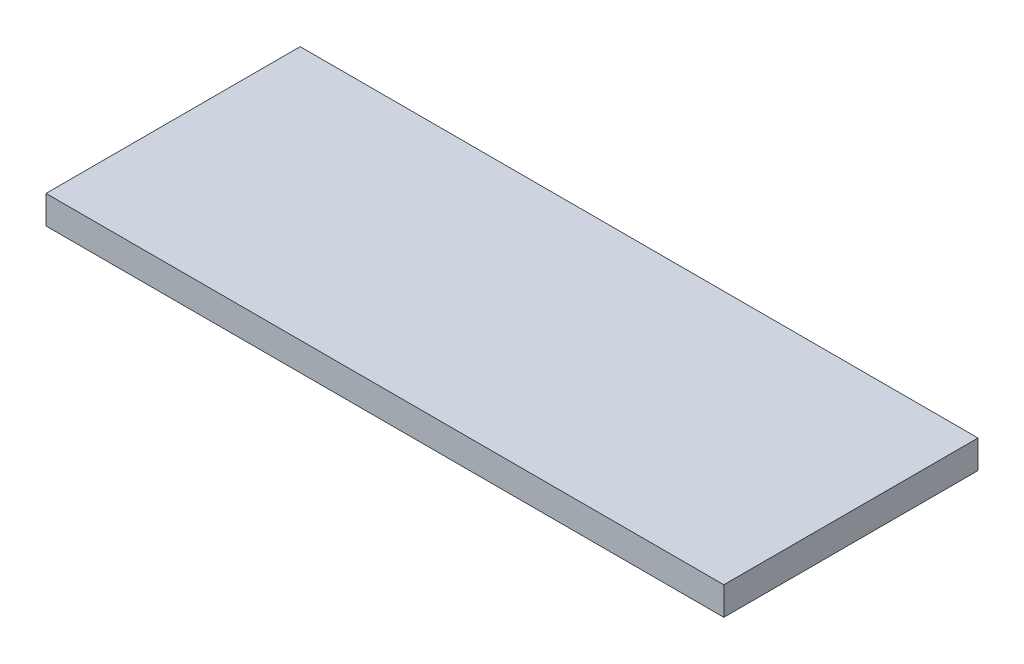
from build123d import *

# Parameters (mm, degrees)
SKETCH1_W           = 304.8
SKETCH1_H           = 114.3
BOSS_EXTRUDE1_DEPTH = 12.7


with BuildPart() as part:
    # Sketch1 → Boss-Extrude1 (new body)
    with BuildSketch(Plane(origin=(0, 0, 0), x_dir=(1, 0, 0), z_dir=(0, 1, 0))):
        with Locations((100.173455507, 39.753138705)):
            Rectangle(SKETCH1_W, SKETCH1_H)
    extrude(amount=BOSS_EXTRUDE1_DEPTH)


solid = part.part
